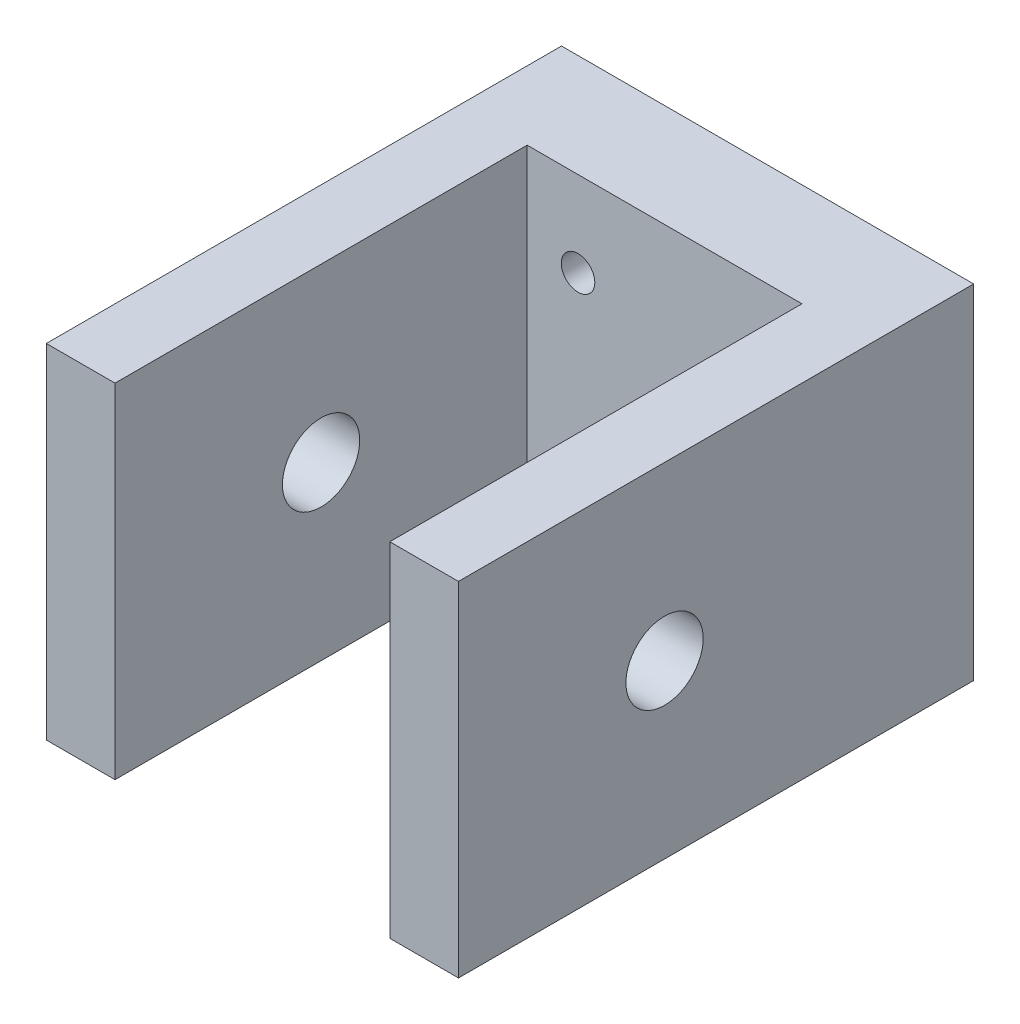
from build123d import *

# Parameters (mm, degrees)
BOSS_EXTRUDE1_DEPTH     = 15.875
M2_5_CLEARANCE_HOLE1_D  = 3.1
F_1_4_CLEARANCE_HOLE1_D = 7.14248
SKETCH7_W               = 6.1468
SKETCH7_H               = 5.4483
CUT_EXTRUDE1_DEPTH      = 1.1771


with BuildPart() as part:
    # Sketch2 → Boss-Extrude1 (new body, symmetric)
    with BuildSketch(Plane(origin=(0, 0, 0), x_dir=(1, 0, 0), z_dir=(0, 1, 0))):
        Polygon((-12.7, 0), (-12.7, -38.1), (-19.05, -38.1), (-19.05, 9.525), (19.05, 9.525), (19.05, -38.1), (12.7, -38.1), (12.7, 0), align=None)
    extrude(amount=BOSS_EXTRUDE1_DEPTH, both=True)

    # M2.5 Clearance Hole1 (through all)
    with Locations(Plane(origin=(0, 0, -9.525), x_dir=(-1, 0, 0), z_dir=(0, 0, -1))):
        with Locations((8, 8), (-8, 8), (-8, -8), (8, -8)):
            Hole(M2_5_CLEARANCE_HOLE1_D / 2)

    # 1/4 Clearance Hole1 (through all)
    with Locations(Plane(origin=(19.05, 0, 0), x_dir=(0, 0, -1), z_dir=(1, 0, 0))):
        with Locations((-19.05, 0)):
            Hole(F_1_4_CLEARANCE_HOLE1_D / 2)

    # Sketch7 → Cut-Extrude1 (cut, symmetric)
    with BuildSketch(Plane.XY.offset(-4.7625)):
        with Locations((8, 8)):
            Rectangle(SKETCH7_W, SKETCH7_H)
        with Locations((-8, 8)):
            Rectangle(SKETCH7_W, SKETCH7_H)
        with Locations((-8, -8)):
            Rectangle(SKETCH7_W, SKETCH7_H)
        with Locations((8, -8)):
            Rectangle(SKETCH7_W, SKETCH7_H)
    extrude(amount=CUT_EXTRUDE1_DEPTH, both=True, mode=Mode.SUBTRACT)


solid = part.part
